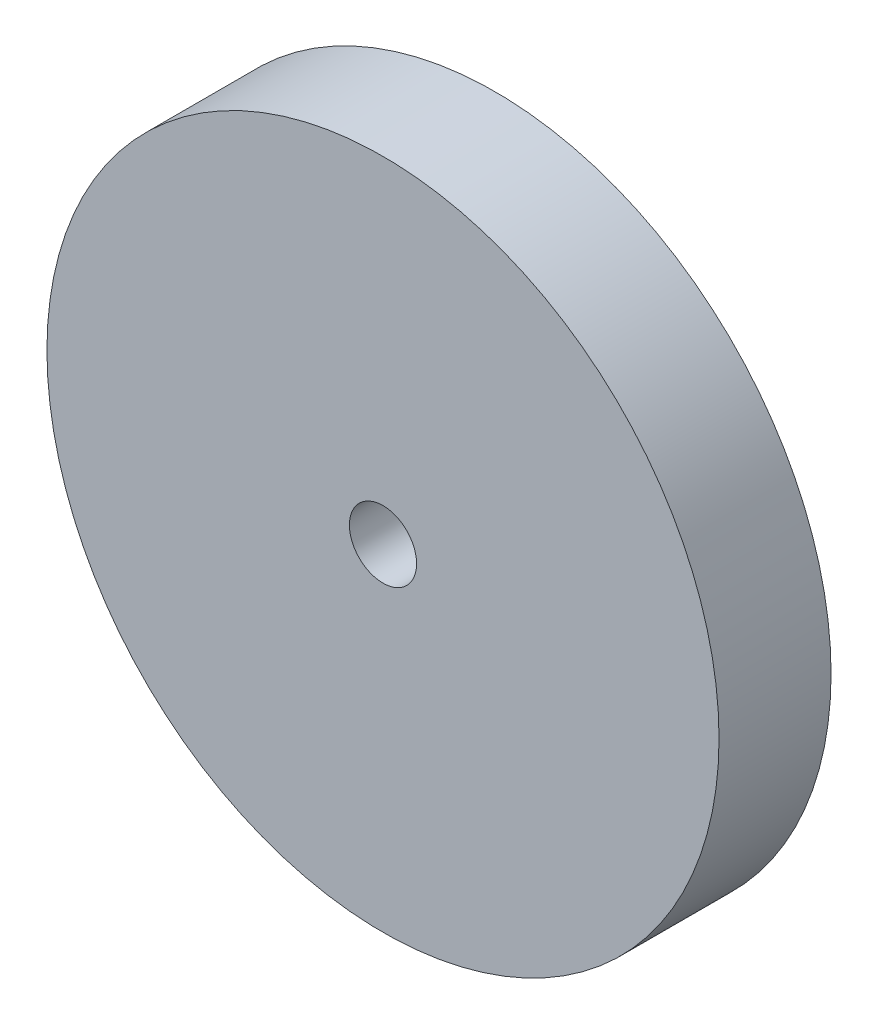
from build123d import *

# Parameters (mm, degrees)
SKETCH1_R           = 60
BOSS_EXTRUDE2_DEPTH = 20
SKETCH2_R           = 6
CUT_EXTRUDE1_DEPTH  = 21


with BuildPart() as part:
    # Sketch1 → Boss-Extrude2 (new body)
    with BuildSketch(Plane.XY):
        Circle(SKETCH1_R)
    extrude(amount=BOSS_EXTRUDE2_DEPTH)

    # Sketch2 → Cut-Extrude1 (cut, through all)
    with BuildSketch(Plane.XY.offset(20)):
        Circle(SKETCH2_R)
    extrude(amount=-CUT_EXTRUDE1_DEPTH, mode=Mode.SUBTRACT)


solid = part.part
